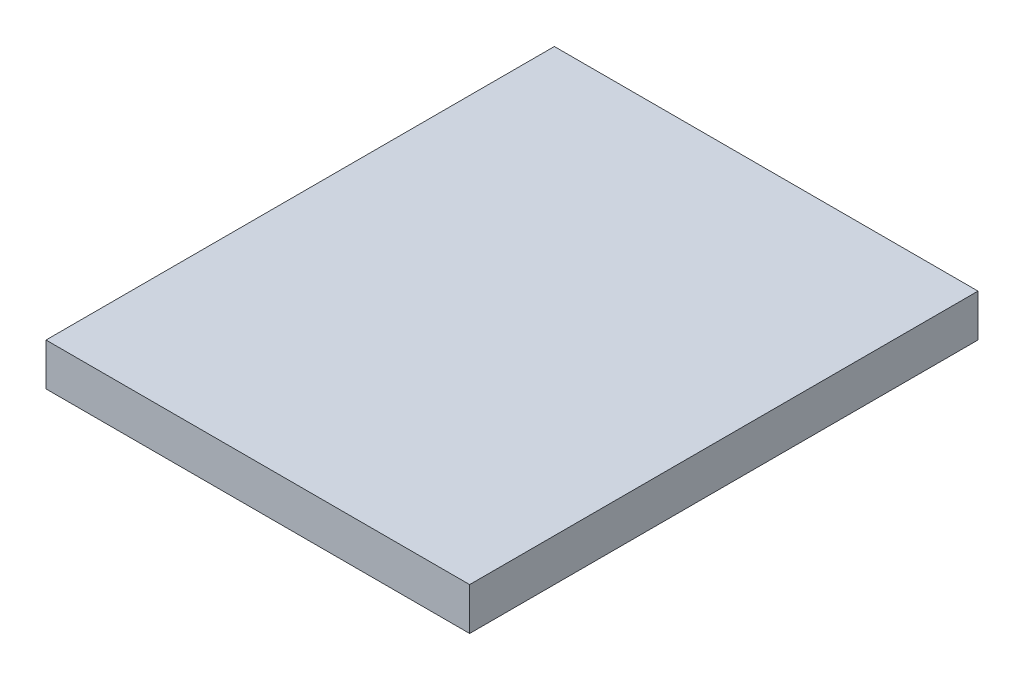
from build123d import *

# Parameters (mm, degrees)
SKETCH1_W           = 15.875
SKETCH1_H           = 19.05
BOSS_EXTRUDE1_DEPTH = 1.5875


with BuildPart() as part:
    # Sketch1 → Boss-Extrude1 (new body)
    with BuildSketch(Plane(origin=(0, 0, 0), x_dir=(1, 0, 0), z_dir=(0, 1, 0))):
        with Locations((7.9375, 9.525)):
            Rectangle(SKETCH1_W, SKETCH1_H)
    extrude(amount=BOSS_EXTRUDE1_DEPTH)


solid = part.part
